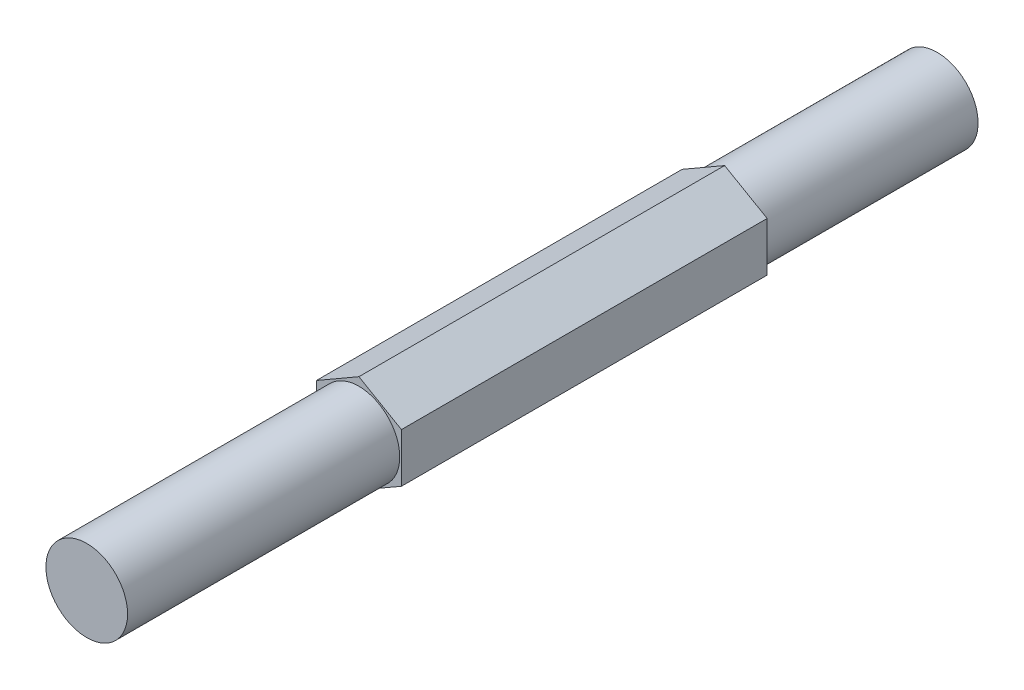
from build123d import *

# Parameters (mm, degrees)
BOSS_EXTRUDE1_DEPTH = 63.5
SKETCH3_OUTSIDE_W   = 21.198
SKETCH3_OUTSIDE_H   = 22.18
SKETCH3_OUTSIDE_R   = 3.048
CUT_EXTRUDE1_DEPTH  = 20.32
SKETCH4_OUTSIDE_W   = 21.198
SKETCH4_OUTSIDE_H   = 22.18
SKETCH4_OUTSIDE_R   = 3.048
CUT_EXTRUDE2_DEPTH  = 15.875


with BuildPart() as part:
    # Sketch2 → Boss-Extrude1 (new body)
    with BuildSketch(Plane.XY):
        Polygon((0, 3.666174209), (-3.175, 1.833087105), (-3.175, -1.833087105), (0, -3.666174209), (3.175, -1.833087105), (3.175, 1.833087105), align=None)
    extrude(amount=BOSS_EXTRUDE1_DEPTH)

    # Sketch3 outside → Cut-Extrude1 (cut)
    with BuildSketch(Plane.XY.offset(63.5)):
        Rectangle(SKETCH3_OUTSIDE_W, SKETCH3_OUTSIDE_H)
        Circle(SKETCH3_OUTSIDE_R, mode=Mode.SUBTRACT)
    extrude(amount=-CUT_EXTRUDE1_DEPTH, mode=Mode.SUBTRACT)

    # Sketch4 outside → Cut-Extrude2 (cut)
    with BuildSketch(Plane(origin=(0, 0, 0), x_dir=(-1, 0, 0), z_dir=(0, 0, -1))):
        Rectangle(SKETCH4_OUTSIDE_W, SKETCH4_OUTSIDE_H)
        Circle(SKETCH4_OUTSIDE_R, mode=Mode.SUBTRACT)
    extrude(amount=-CUT_EXTRUDE2_DEPTH, mode=Mode.SUBTRACT)


solid = part.part
